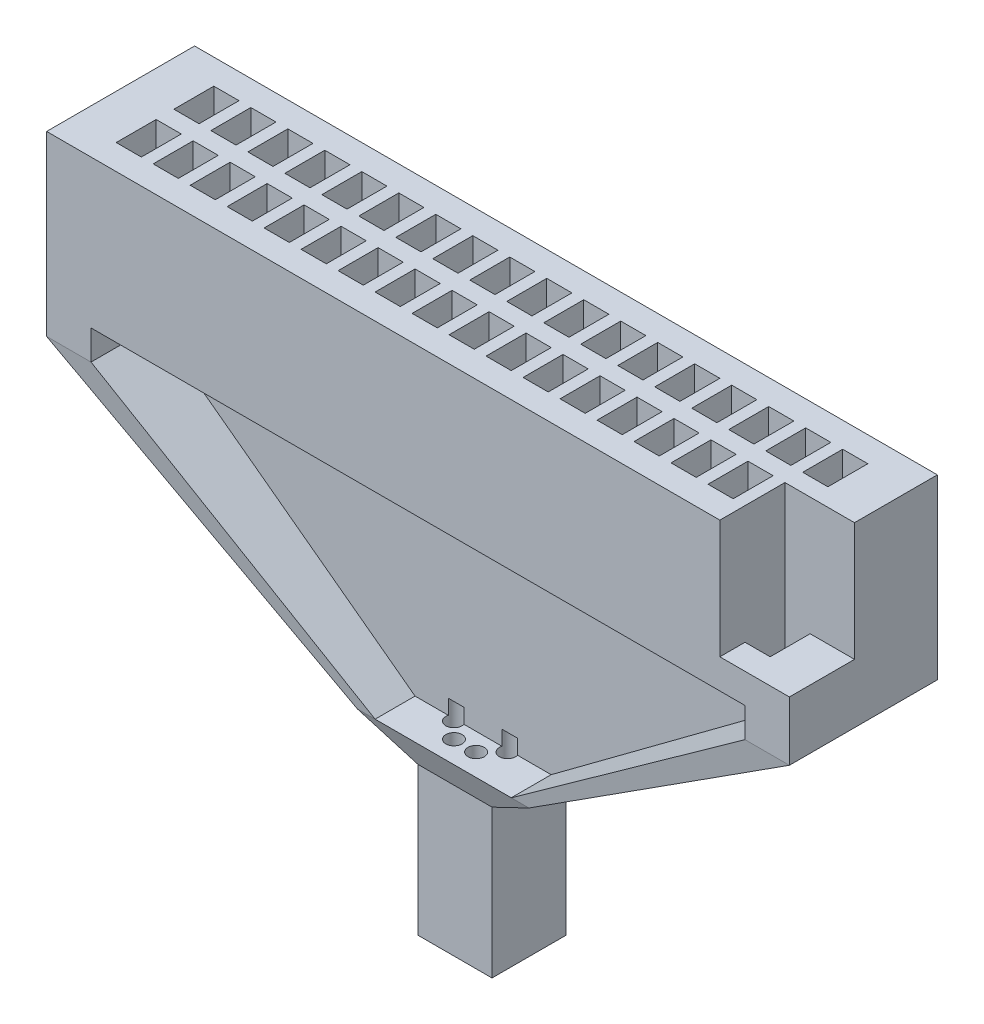
from build123d import *

# Parameters (mm, degrees)
MAIN_BLOCK_W           = 12.7508
MAIN_BLOCK_H           = 2.54
WELL_BLOCK_DEPTH       = 2.54
TOP_HOLES_W            = 0.4318
TOP_HOLES_H            = 0.6858
OMNETICS_WELLS_DEPTH   = 2.54
SKETCH8_W              = 0.762
SKETCH8_H              = 2.54
SUPPORTBEAM1_DEPTH     = 0.508
SKETCH10_W             = 0.762
SKETCH10_H             = 2.54
SUPPORTBEAM2_DEPTH     = 0.508
SKETCH7_W              = 0.3048
SKETCH7_H              = 1.77800034
SKETCH5_W              = 11.226700613
SKETCH5_H              = 0.3048
WALL_DIVIDER_DEPTH     = 0.508
SKETCH6_W              = 2.336782461
SKETCH6_H              = 0.3048
SKETCH12_W             = 2.9464
SKETCH12_H             = 1.77800034
SKETCH13_W             = 1.27
SKETCH13_H             = 1.27
SKETCH13_3_W           = 1.27
SKETCH13_3_H           = 1.27
TETRODE_FUNNEL_DEPTH   = 2.54
SKETCH17_W             = 1.1938
SKETCH17_H             = 1.1176
GROUND_WIRE_HOLE_DEPTH = 2.032
SKETCH18_R             = 0.1397
TETRODES_DEPTH         = 3.302


with BuildPart() as part:
    # main_block → well_block (new body)
    with BuildSketch(Plane(origin=(0, 0, 0), x_dir=(1, 0, 0), z_dir=(0, 1, 0))):
        with Locations((0.756592766, -0.05080017)):
            Rectangle(MAIN_BLOCK_W, MAIN_BLOCK_H)
    extrude(amount=-WELL_BLOCK_DEPTH)

    # top_holes → omnetics_wells (cut)
    with BuildSketch(Plane(origin=(0, 0, 0), x_dir=(1, 0, 0), z_dir=(0, 1, 0))):
        with Locations((6.154092766, 0.44449983)):
            Rectangle(TOP_HOLES_W, TOP_HOLES_H)
        with Locations((5.519098613, 0.44449983)):
            Rectangle(TOP_HOLES_W, TOP_HOLES_H)
        with Locations((4.884104459, 0.44449983)):
            Rectangle(TOP_HOLES_W, TOP_HOLES_H)
        with Locations((4.249110305, 0.44449983)):
            Rectangle(TOP_HOLES_W, TOP_HOLES_H)
        with Locations((3.614116151, 0.44449983)):
            Rectangle(TOP_HOLES_W, TOP_HOLES_H)
        with Locations((2.979121998, 0.44449983)):
            Rectangle(TOP_HOLES_W, TOP_HOLES_H)
        with Locations((2.344127844, 0.44449983)):
            Rectangle(TOP_HOLES_W, TOP_HOLES_H)
        with Locations((1.70913369, 0.44449983)):
            Rectangle(TOP_HOLES_W, TOP_HOLES_H)
        with Locations((1.074139537, 0.44449983)):
            Rectangle(TOP_HOLES_W, TOP_HOLES_H)
        with Locations((0.439145383, 0.44449983)):
            Rectangle(TOP_HOLES_W, TOP_HOLES_H)
        with Locations((-0.195848771, 0.44449983)):
            Rectangle(TOP_HOLES_W, TOP_HOLES_H)
        with Locations((-0.830842925, 0.44449983)):
            Rectangle(TOP_HOLES_W, TOP_HOLES_H)
        with Locations((-1.465837078, 0.44449983)):
            Rectangle(TOP_HOLES_W, TOP_HOLES_H)
        with Locations((-2.100831232, 0.44449983)):
            Rectangle(TOP_HOLES_W, TOP_HOLES_H)
        with Locations((-2.735825386, 0.44449983)):
            Rectangle(TOP_HOLES_W, TOP_HOLES_H)
        with Locations((-3.370819539, 0.44449983)):
            Rectangle(TOP_HOLES_W, TOP_HOLES_H)
        with Locations((-4.005813693, 0.44449983)):
            Rectangle(TOP_HOLES_W, TOP_HOLES_H)
        with Locations((-4.640807847, 0.44449983)):
            Rectangle(TOP_HOLES_W, TOP_HOLES_H)
        with Locations((5.519098613, -0.54610017)):
            Rectangle(TOP_HOLES_W, TOP_HOLES_H)
        with Locations((4.884104459, -0.54610017)):
            Rectangle(TOP_HOLES_W, TOP_HOLES_H)
        with Locations((4.249110305, -0.54610017)):
            Rectangle(TOP_HOLES_W, TOP_HOLES_H)
        with Locations((3.614116151, -0.54610017)):
            Rectangle(TOP_HOLES_W, TOP_HOLES_H)
        with Locations((2.979121998, -0.54610017)):
            Rectangle(TOP_HOLES_W, TOP_HOLES_H)
        with Locations((2.344127844, -0.54610017)):
            Rectangle(TOP_HOLES_W, TOP_HOLES_H)
        with Locations((1.70913369, -0.54610017)):
            Rectangle(TOP_HOLES_W, TOP_HOLES_H)
        with Locations((1.074139537, -0.54610017)):
            Rectangle(TOP_HOLES_W, TOP_HOLES_H)
        with Locations((0.439145383, -0.54610017)):
            Rectangle(TOP_HOLES_W, TOP_HOLES_H)
        with Locations((-0.195848771, -0.54610017)):
            Rectangle(TOP_HOLES_W, TOP_HOLES_H)
        with Locations((-0.830842925, -0.54610017)):
            Rectangle(TOP_HOLES_W, TOP_HOLES_H)
        with Locations((-1.465837078, -0.54610017)):
            Rectangle(TOP_HOLES_W, TOP_HOLES_H)
        with Locations((-2.100831232, -0.54610017)):
            Rectangle(TOP_HOLES_W, TOP_HOLES_H)
        with Locations((-2.735825386, -0.54610017)):
            Rectangle(TOP_HOLES_W, TOP_HOLES_H)
        with Locations((-3.370819539, -0.54610017)):
            Rectangle(TOP_HOLES_W, TOP_HOLES_H)
        with Locations((-4.005813693, -0.54610017)):
            Rectangle(TOP_HOLES_W, TOP_HOLES_H)
        with Locations((-4.640807847, -0.54610017)):
            Rectangle(TOP_HOLES_W, TOP_HOLES_H)
        with Locations((6.154092766, -0.54610017)):
            Rectangle(TOP_HOLES_W, TOP_HOLES_H)
    extrude(amount=-OMNETICS_WELLS_DEPTH, mode=Mode.SUBTRACT)

    # Sketch8 → supportbeam1 (add)
    with BuildSketch(Plane.XZ.offset(2.54)):
        with Locations((-5.237707847, 0.05080017)):
            Rectangle(SKETCH8_W, SKETCH8_H)
    extrude(amount=SUPPORTBEAM1_DEPTH)

    # Sketch10 → supportbeam2 (add)
    with BuildSketch(Plane.XZ.offset(2.54)):
        with Locations((6.750992766, 0.05080017)):
            Rectangle(SKETCH10_W, SKETCH10_H)
    extrude(amount=SUPPORTBEAM2_DEPTH)

    # Sketch9 → section 0 of arm1
    with BuildSketch(Plane(origin=(0, -6.35, 0), x_dir=(1, 0, 0), z_dir=(0, 1, 0)), mode=Mode.PRIVATE) as arm1_s0:
        Polygon((1.92503369, -0.88900017), (1.924934303, 0.88900017), (2.229734303, 0.889017208), (2.22983369, -0.888983133), align=None)
    # loft up to a face of the part (arm1)
    loft([arm1_s0.sketch, part.faces().sort_by_distance((6.750992766, -3.048, 0.05080017))[0]])

    # Sketch7 → section 0 of arm2
    with BuildSketch(Plane(origin=(0, -6.35, 0), x_dir=(1, 0, 0), z_dir=(0, 1, 0)), mode=Mode.PRIVATE) as arm2_s0:
        with Locations((-0.564148771, 0)):
            Rectangle(SKETCH7_W, SKETCH7_H)
    # loft up to a face of the part (arm2)
    loft([arm2_s0.sketch, part.faces().sort_by_distance((-5.237707847, -3.048, 0.05080017))[0]])

    # Sketch5 → wall_divider (add)
    with BuildSketch(Plane.XZ.offset(2.54)):
        with Locations((0.75664246, 0.05080017)):
            Rectangle(SKETCH5_W, SKETCH5_H)
    extrude(amount=WALL_DIVIDER_DEPTH)

    # Sketch6 → section 1 of wall_divider2
    with BuildSketch(Plane(origin=(0, -6.35, 0), x_dir=(1, 0, 0), z_dir=(0, 1, 0)), mode=Mode.PRIVATE) as wall_divider2_s1:
        with Locations((0.756642459, -0.05080017)):
            Rectangle(SKETCH6_W, SKETCH6_H)
    # loft from a face of the part (wall_divider2)
    loft([part.faces().sort_by_distance((0.75664246, -3.048, 0.05080017))[0], wall_divider2_s1.sketch])

    # Sketch12 → exit_base section 0
    with BuildSketch(Plane(origin=(0, -6.35, 0), x_dir=(1, 0, 0), z_dir=(0, 1, 0))):
        with Locations((0.756651229, 0)):
            Rectangle(SKETCH12_W, SKETCH12_H)
    # Sketch13 → exit_base section 1
    with BuildSketch(Plane(origin=(0, -6.858, 0), x_dir=(1, 0, 0), z_dir=(0, 1, 0))):
        with Locations((0.756639537, -0.050800172)):
            Rectangle(SKETCH13_W, SKETCH13_H)
    loft()

    # Sketch13_3 → tetrode_funnel (add)
    with BuildSketch(Plane(origin=(0, -6.858, 0), x_dir=(1, 0, 0), z_dir=(0, 1, 0))):
        with Locations((0.756639537, -0.050800172)):
            Rectangle(SKETCH13_3_W, SKETCH13_3_H)
    extrude(amount=-TETRODE_FUNNEL_DEPTH)

    # Sketch17 → ground_wire_hole (cut)
    with BuildSketch(Plane(origin=(0, 0, 0), x_dir=(1, 0, 0), z_dir=(0, 1, 0))):
        with Locations((6.535092766, -0.76200017)):
            Rectangle(SKETCH17_W, SKETCH17_H)
    extrude(amount=-GROUND_WIRE_HOLE_DEPTH, mode=Mode.SUBTRACT)

    # Sketch18 → tetrodes (cut)
    with BuildSketch(Plane(origin=(0, -9.398, 0), x_dir=(-1, 0, 0), z_dir=(0, -1, 0))):
        with Locations((-1.213839537, -0.241300172)):
            Circle(SKETCH18_R)
        with Locations((-1.213839537, 0.139699828)):
            Circle(SKETCH18_R)
        with Locations((-0.944431853, 0.409107512)):
            Circle(SKETCH18_R)
        with Locations((-0.563431853, 0.409107512)):
            Circle(SKETCH18_R)
        with Locations((-0.294024169, 0.139699828)):
            Circle(SKETCH18_R)
        with Locations((-0.294024169, -0.241300172)):
            Circle(SKETCH18_R)
        with Locations((-0.563431853, -0.510707855)):
            Circle(SKETCH18_R)
        with Locations((-0.944431853, -0.510707855)):
            Circle(SKETCH18_R)
    extrude(amount=-TETRODES_DEPTH, mode=Mode.SUBTRACT)


solid = part.part
